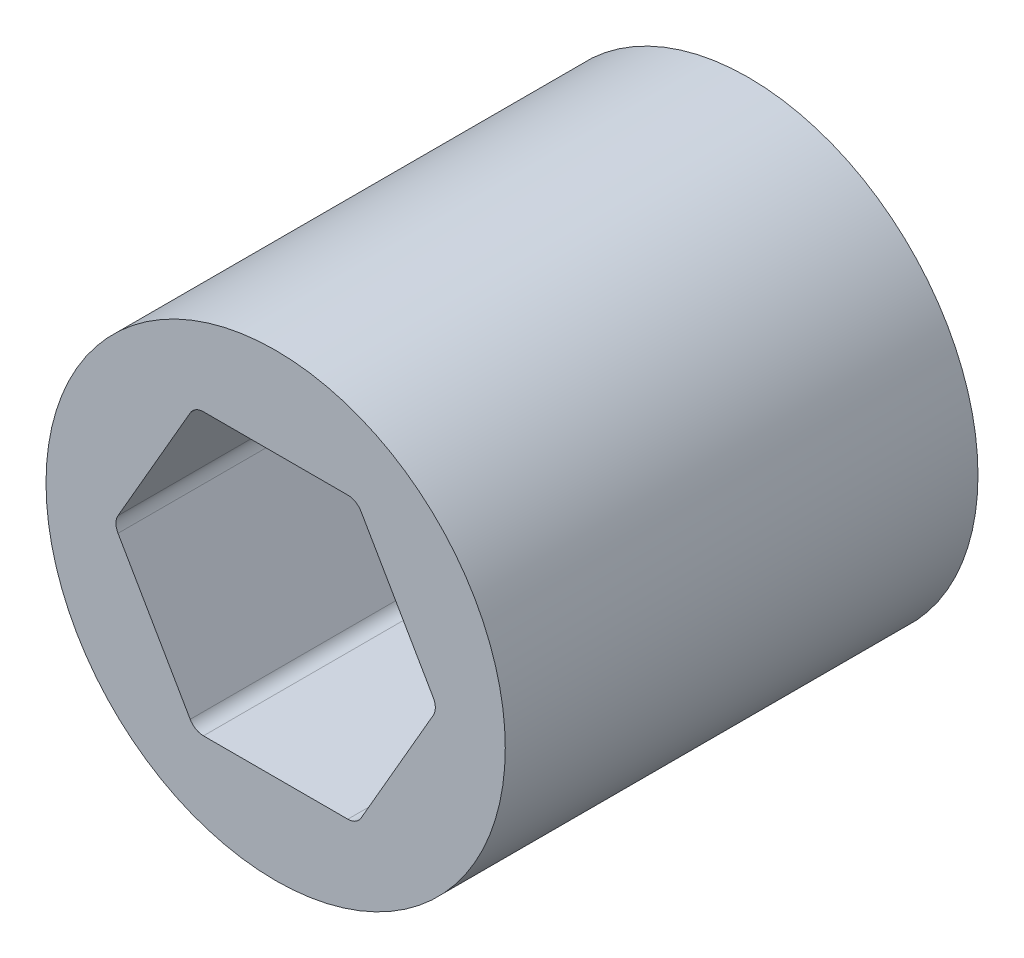
from build123d import *

# Parameters (mm, degrees)
CROQUIS1_R              = 11.43
SALIENTE_EXTRUIR1_DEPTH = 11.764075024


with BuildPart() as part:
    # Croquis1 → Saliente-Extruir1 (new body, symmetric)
    with BuildSketch(Plane.XY):
        Circle(CROQUIS1_R)
        with BuildLine():
            Line((3.592850725, 6.985), (-3.592850725, 6.985))
            ThreePointArc((-3.592850725, 6.985), (-3.973850725, 6.882911358), (-4.252762083, 6.604))
            Line((-4.252762083, 6.604), (-7.845612808, 0.381))
            ThreePointArc((-7.845612808, 0.381), (-7.94770145, 0), (-7.845612808, -0.381))
            Line((-7.845612808, -0.381), (-4.252762083, -6.604))
            ThreePointArc((-4.252762083, -6.604), (-3.973850725, -6.882911358), (-3.592850725, -6.985))
            Line((-3.592850725, -6.985), (3.592850725, -6.985))
            ThreePointArc((3.592850725, -6.985), (3.973850725, -6.882911358), (4.252762083, -6.604))
            Line((4.252762083, -6.604), (7.845612808, -0.381))
            ThreePointArc((7.845612808, -0.381), (7.94770145, 0), (7.845612808, 0.381))
            Line((7.845612808, 0.381), (4.252762083, 6.604))
            ThreePointArc((4.252762083, 6.604), (3.973850725, 6.882911358), (3.592850725, 6.985))
        make_face(mode=Mode.SUBTRACT)
    extrude(amount=SALIENTE_EXTRUIR1_DEPTH, both=True)


solid = part.part
